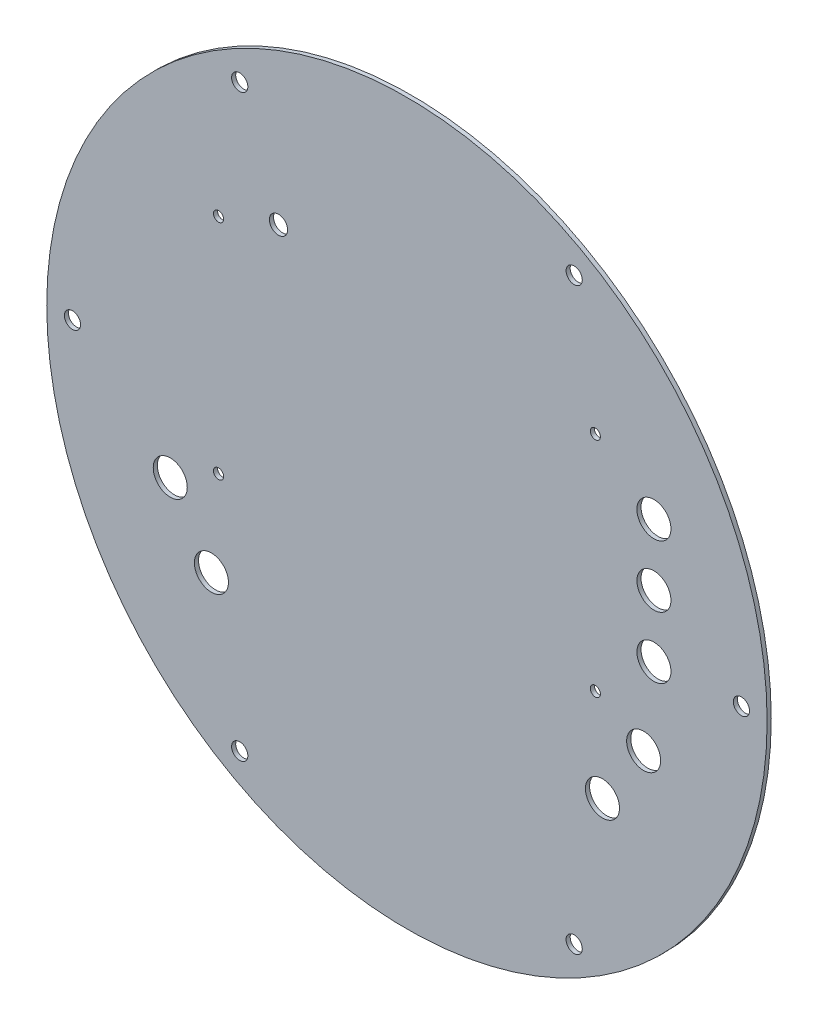
from build123d import *

# Parameters (mm, degrees)
SKETCH1_R           = 88.9
SKETCH1_R_2         = 2
BOSS_EXTRUDE1_DEPTH = 1.016
SKETCH3_R           = 1.25
SKETCH3_R_2         = 2.25
CUT_EXTRUDE2_DEPTH  = 3.175
SKETCH4_R           = 4.2
CUT_EXTRUDE3_DEPTH  = 10


with BuildPart() as part:
    # Sketch1 → Boss-Extrude1 (new body)
    with BuildSketch(Plane.XY):
        Circle(SKETCH1_R)
        with Locations((41.275, 71.490397082)):
            Circle(SKETCH1_R_2, mode=Mode.SUBTRACT)
        with Locations((82.55, 0)):
            Circle(SKETCH1_R_2, mode=Mode.SUBTRACT)
        with Locations((41.275, -71.490397082)):
            Circle(SKETCH1_R_2, mode=Mode.SUBTRACT)
        with Locations((-41.275, -71.490397082)):
            Circle(SKETCH1_R_2, mode=Mode.SUBTRACT)
        with Locations((-82.55, 0)):
            Circle(SKETCH1_R_2, mode=Mode.SUBTRACT)
        with Locations((-41.275, 71.490397082)):
            Circle(SKETCH1_R_2, mode=Mode.SUBTRACT)
    extrude(amount=BOSS_EXTRUDE1_DEPTH)

    # Sketch3 → Cut-Extrude2 (cut)
    with BuildSketch(Plane.XY.offset(1.016)):
        with Locations((-46.5, 40.2)):
            Circle(SKETCH3_R)
        with Locations((46.5, 40.2)):
            Circle(SKETCH3_R)
        with Locations((46.5, -14.8)):
            Circle(SKETCH3_R)
        with Locations((-46.5, -14.8)):
            Circle(SKETCH3_R)
        with Locations((-31.700000009, 45.8)):
            Circle(SKETCH3_R_2)
    extrude(amount=-CUT_EXTRUDE2_DEPTH, mode=Mode.SUBTRACT)

    # Sketch4 → Cut-Extrude3 (cut)
    with BuildSketch(Plane.XY.offset(1.016)):
        with Locations((60.96, 29.21)):
            Circle(SKETCH4_R)
        with Locations((60.96, 13.97)):
            Circle(SKETCH4_R)
        with Locations((60.96, -1.27)):
            Circle(SKETCH4_R)
        with Locations((58.42, -21.59)):
            Circle(SKETCH4_R)
        with Locations((48.26, -36.83)):
            Circle(SKETCH4_R)
        with Locations((-58.42, -21.59)):
            Circle(SKETCH4_R)
        with Locations((-48.26, -36.83)):
            Circle(SKETCH4_R)
    extrude(amount=-CUT_EXTRUDE3_DEPTH, mode=Mode.SUBTRACT)


solid = part.part
